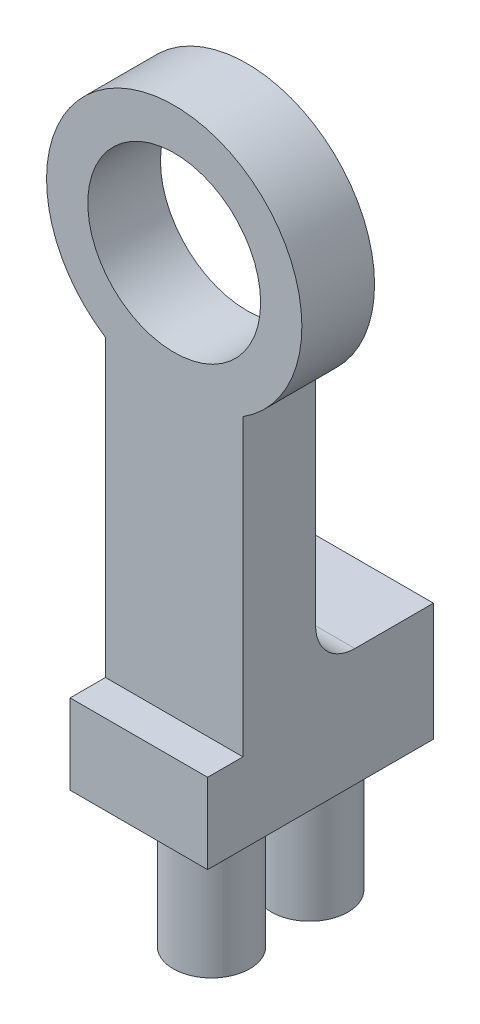
from build123d import *

# Parameters (mm, degrees)
BOSS_EXTRUDE1_DEPTH     = 3.7
SKETCH2_W               = 0.6
SKETCH2_H               = 16.95
CUT_EXTRUDE1_DEPTH      = 10
CUT_EXTRUDE1_DEPTH_BACK = 10
SKETCH3_R               = 2.95
SKETCH3_R_2             = 1.5
BOSS_EXTRUDE2_DEPTH     = 3.1
SKETCH4_R               = 2.5
CUT_EXTRUDE2_DEPTH      = 1.5
SKETCH5_R               = 1.5
BOSS_EXTRUDE3_DEPTH     = 0.4
SKETCH6_R               = 2.95
BOSS_EXTRUDE4_DEPTH     = 2.4
SKETCH7_W               = 22.104564564
SKETCH7_H               = 50.546801486
CUT_EXTRUDE3_DEPTH      = 0.6
SKETCH8_R               = 1.5
BOSS_EXTRUDE5_DEPTH     = 2.6
SKETCH9_R               = 5.5
SKETCH9_R_2             = 3.5
BOSS_EXTRUDE6_DEPTH     = 5.5
SKETCH10_W              = 7
SKETCH10_H              = 7
CUT_EXTRUDE4_DEPTH      = 5.5
SKETCH11_W              = 20.865326807
SKETCH11_H              = 17.809349761
CUT_EXTRUDE5_DEPTH      = 10
SKETCH12_W              = 7
SKETCH12_H              = 6
BOSS_EXTRUDE7_DEPTH     = 6
FILLET1_R               = 2
SKETCH13_R              = 1.95
BOSS_EXTRUDE8_DEPTH     = 7
SKETCH14_R              = 2.95
CUT_EXTRUDE6_DEPTH      = 1.5
SKETCH15_R              = 2.95
BOSS_EXTRUDE9_DEPTH     = 4
SKETCH16_R              = 4.4
CUT_EXTRUDE7_DEPTH      = 34.729104643
SKETCH19_W              = 21.129428132
SKETCH19_H              = 30.590898574
CUT_EXTRUDE10_DEPTH     = 0.3


with BuildPart() as part:
    # Sketch1 → Boss-Extrude1 (new body)
    with BuildSketch(Plane.XY):
        with BuildLine():
            ThreePointArc((3.5, -5.477225575), (0, -6.5), (-3.5, -5.477225575))
            Line((-3.5, -5.477225575), (-3.5, -29.522774425))
            ThreePointArc((-3.5, -29.522774425), (0, -28.5), (3.5, -29.522774425))
            Line((3.5, -29.522774425), (3.5, -5.477225575))
        make_face()
        with BuildLine():
            ThreePointArc((-3.5, -4.242640687), (-4.974937186, -2.34520788), (-5.5, 0))
            ThreePointArc((-5.5, 0), (-4.387482194, 3.31662479), (-1.5, 5.291502622))
            ThreePointArc((-1.5, 5.291502622), (0, 5.5), (1.5, 5.291502622))
            ThreePointArc((1.5, 5.291502622), (4.387482194, 3.31662479), (5.5, 0))
            ThreePointArc((5.5, 0), (4.974937186, -2.34520788), (3.5, -4.242640687))
            Line((3.5, -4.242640687), (3.5, -5.477225575))
            ThreePointArc((3.5, -5.477225575), (5.700877125, -3.122498999), (6.5, 0))
            ThreePointArc((6.5, 0), (-3.122498999, 5.700877125), (-3.5, -5.477225575))
            Line((-3.5, -5.477225575), (-3.5, -4.242640687))
        make_face()
        with BuildLine():
            ThreePointArc((3.5, -4.242640687), (0, -5.5), (-3.5, -4.242640687))
            Line((-3.5, -4.242640687), (-3.5, -5.477225575))
            ThreePointArc((-3.5, -5.477225575), (0, -6.5), (3.5, -5.477225575))
            Line((3.5, -5.477225575), (3.5, -4.242640687))
        make_face()
        with BuildLine():
            ThreePointArc((3.5, 0), (0, -3.5), (-3.5, 0))
            Line((-3.5, 0), (-3.5, -4.242640687))
            ThreePointArc((-3.5, -4.242640687), (0, -5.5), (3.5, -4.242640687))
            Line((3.5, -4.242640687), (3.5, 0))
        make_face()
        with BuildLine():
            ThreePointArc((-3.5, -4.242640687), (-4.974937186, -2.34520788), (-5.5, 0))
            ThreePointArc((-5.5, 0), (-4.387482194, 3.31662479), (-1.5, 5.291502622))
            ThreePointArc((-1.5, 5.291502622), (0, 5.5), (1.5, 5.291502622))
            ThreePointArc((1.5, 5.291502622), (4.387482194, 3.31662479), (5.5, 0))
            ThreePointArc((5.5, 0), (4.974937186, -2.34520788), (3.5, -4.242640687))
            Line((3.5, -4.242640687), (3.5, -5.477225575))
            ThreePointArc((3.5, -5.477225575), (5.700877125, -3.122498999), (6.5, 0))
            ThreePointArc((6.5, 0), (-3.122498999, 5.700877125), (-3.5, -5.477225575))
            Line((-3.5, -5.477225575), (-3.5, -4.242640687))
        make_face()
        with BuildLine():
            ThreePointArc((3.5, -4.242640687), (0, -5.5), (-3.5, -4.242640687))
            Line((-3.5, -4.242640687), (-3.5, -5.477225575))
            ThreePointArc((-3.5, -5.477225575), (0, -6.5), (3.5, -5.477225575))
            Line((3.5, -5.477225575), (3.5, -4.242640687))
        make_face()
        with BuildLine():
            ThreePointArc((3.5, -29.522774425), (0, -28.5), (-3.5, -29.522774425))
            Line((-3.5, -29.522774425), (-3.5, -30.757359313))
            ThreePointArc((-3.5, -30.757359313), (0, -29.5), (3.5, -30.757359313))
            Line((3.5, -30.757359313), (3.5, -29.522774425))
        make_face()
        with BuildLine():
            Line((-3.5, -30.757359313), (-3.5, -29.522774425))
            ThreePointArc((-3.5, -29.522774425), (-3.122498999, -40.700877125), (6.5, -35))
            ThreePointArc((6.5, -35), (5.700877125, -31.877501001), (3.5, -29.522774425))
            Line((3.5, -29.522774425), (3.5, -30.757359313))
            ThreePointArc((3.5, -30.757359313), (4.974937186, -32.65479212), (5.5, -35))
            ThreePointArc((5.5, -35), (4.387482194, -38.31662479), (1.5, -40.291502622))
            ThreePointArc((1.5, -40.291502622), (0, -40.5), (-1.5, -40.291502622))
            ThreePointArc((-1.5, -40.291502622), (-4.387482194, -38.31662479), (-5.5, -35))
            ThreePointArc((-5.5, -35), (-4.974937186, -32.65479212), (-3.5, -30.757359313))
        make_face()
        with BuildLine():
            ThreePointArc((3.5, -29.522774425), (0, -28.5), (-3.5, -29.522774425))
            Line((-3.5, -29.522774425), (-3.5, -30.757359313))
            ThreePointArc((-3.5, -30.757359313), (0, -29.5), (3.5, -30.757359313))
            Line((3.5, -30.757359313), (3.5, -29.522774425))
        make_face()
        with BuildLine():
            Line((-3.5, -30.757359313), (-3.5, -29.522774425))
            ThreePointArc((-3.5, -29.522774425), (-3.122498999, -40.700877125), (6.5, -35))
            ThreePointArc((6.5, -35), (5.700877125, -31.877501001), (3.5, -29.522774425))
            Line((3.5, -29.522774425), (3.5, -30.757359313))
            ThreePointArc((3.5, -30.757359313), (4.974937186, -32.65479212), (5.5, -35))
            ThreePointArc((5.5, -35), (4.387482194, -38.31662479), (1.5, -40.291502622))
            ThreePointArc((1.5, -40.291502622), (0, -40.5), (-1.5, -40.291502622))
            ThreePointArc((-1.5, -40.291502622), (-4.387482194, -38.31662479), (-5.5, -35))
            ThreePointArc((-5.5, -35), (-4.974937186, -32.65479212), (-3.5, -30.757359313))
        make_face()
        with BuildLine():
            ThreePointArc((3.5, -30.757359313), (0, -29.5), (-3.5, -30.757359313))
            Line((-3.5, -30.757359313), (-3.5, -35))
            ThreePointArc((-3.5, -35), (0, -31.5), (3.5, -35))
            Line((3.5, -35), (3.5, -30.757359313))
        make_face()
        with BuildLine():
            Line((-3.5, -35), (-3.5, -30.757359313))
            ThreePointArc((-3.5, -30.757359313), (-4.974937186, -32.65479212), (-5.5, -35))
            Line((-5.5, -35), (-3.5, -35))
        make_face()
        with BuildLine():
            ThreePointArc((5.5, -35), (4.974937186, -32.65479212), (3.5, -30.757359313))
            Line((3.5, -30.757359313), (3.5, -35))
            Line((3.5, -35), (5.5, -35))
        make_face()
        with BuildLine():
            ThreePointArc((3.5, -35), (0, -31.5), (-3.5, -35))
            Line((-3.5, -35), (-2.95, -35))
            ThreePointArc((-2.95, -35), (0, -32.05), (2.95, -35))
            Line((2.95, -35), (3.5, -35))
        make_face()
        with BuildLine():
            Line((-2.95, -35), (-3.5, -35))
            ThreePointArc((-3.5, -35), (-2.958039892, -36.870828693), (-1.5, -38.16227766))
            ThreePointArc((-1.5, -38.16227766), (0, -38.5), (1.5, -38.16227766))
            ThreePointArc((1.5, -38.16227766), (2.958039892, -36.870828693), (3.5, -35))
            Line((3.5, -35), (2.95, -35))
            ThreePointArc((2.95, -35), (0, -37.95), (-2.95, -35))
        make_face()
        with BuildLine():
            ThreePointArc((3.5, -35), (0, -31.5), (-3.5, -35))
            Line((-3.5, -35), (-2.95, -35))
            ThreePointArc((-2.95, -35), (0, -32.05), (2.95, -35))
            Line((2.95, -35), (3.5, -35))
        make_face()
        with BuildLine():
            Line((-2.95, -35), (-3.5, -35))
            ThreePointArc((-3.5, -35), (-2.958039892, -36.870828693), (-1.5, -38.16227766))
            ThreePointArc((-1.5, -38.16227766), (0, -38.5), (1.5, -38.16227766))
            ThreePointArc((1.5, -38.16227766), (2.958039892, -36.870828693), (3.5, -35))
            Line((3.5, -35), (2.95, -35))
            ThreePointArc((2.95, -35), (0, -37.95), (-2.95, -35))
        make_face()
        with BuildLine():
            Line((-1.5, 5.291502622), (-1.5, 3.16227766))
            ThreePointArc((-1.5, 3.16227766), (0, 3.5), (1.5, 3.16227766))
            Line((1.5, 3.16227766), (1.5, 5.291502622))
            ThreePointArc((1.5, 5.291502622), (0, 5.5), (-1.5, 5.291502622))
        make_face()
        with BuildLine():
            Line((-3.5, -4.242640687), (-3.5, 0))
            Line((-3.5, 0), (-5.5, 0))
            ThreePointArc((-5.5, 0), (-4.974937186, -2.34520788), (-3.5, -4.242640687))
        make_face()
        with BuildLine():
            Line((5.5, 0), (3.5, 0))
            Line((3.5, 0), (3.5, -4.242640687))
            ThreePointArc((3.5, -4.242640687), (4.974937186, -2.34520788), (5.5, 0))
        make_face()
        with BuildLine():
            ThreePointArc((-1.5, 3.16227766), (-2.958039892, 1.870828693), (-3.5, 0))
            Line((-3.5, 0), (-2.95, 0))
            ThreePointArc((-2.95, 0), (0, 2.95), (2.95, 0))
            Line((2.95, 0), (3.5, 0))
            ThreePointArc((3.5, 0), (2.958039892, 1.870828693), (1.5, 3.16227766))
            ThreePointArc((1.5, 3.16227766), (0, 3.5), (-1.5, 3.16227766))
        make_face()
        with BuildLine():
            Line((-2.95, 0), (-3.5, 0))
            ThreePointArc((-3.5, 0), (0, -3.5), (3.5, 0))
            Line((3.5, 0), (2.95, 0))
            ThreePointArc((2.95, 0), (0, -2.95), (-2.95, 0))
        make_face()
        with BuildLine():
            ThreePointArc((-1.5, 3.16227766), (-2.958039892, 1.870828693), (-3.5, 0))
            Line((-3.5, 0), (-2.95, 0))
            ThreePointArc((-2.95, 0), (0, 2.95), (2.95, 0))
            Line((2.95, 0), (3.5, 0))
            ThreePointArc((3.5, 0), (2.958039892, 1.870828693), (1.5, 3.16227766))
            ThreePointArc((1.5, 3.16227766), (0, 3.5), (-1.5, 3.16227766))
        make_face()
        with BuildLine():
            Line((-2.95, 0), (-3.5, 0))
            ThreePointArc((-3.5, 0), (0, -3.5), (3.5, 0))
            Line((3.5, 0), (2.95, 0))
            ThreePointArc((2.95, 0), (0, -2.95), (-2.95, 0))
        make_face()
        with BuildLine():
            ThreePointArc((1.5, -38.16227766), (0, -38.5), (-1.5, -38.16227766))
            Line((-1.5, -38.16227766), (-1.5, -40.291502622))
            ThreePointArc((-1.5, -40.291502622), (0, -40.5), (1.5, -40.291502622))
            Line((1.5, -40.291502622), (1.5, -38.16227766))
        make_face()
    extrude(amount=BOSS_EXTRUDE1_DEPTH)

    # Sketch2 → Cut-Extrude1 (cut, two sides)
    with BuildSketch(Plane(origin=(0, 0, 0), x_dir=(0, 0, -1), z_dir=(1, 0, 0))) as cut_extrude1_sk:
        with Locations((-3.4, -33.025)):
            Rectangle(SKETCH2_W, SKETCH2_H)
    extrude(amount=CUT_EXTRUDE1_DEPTH, mode=Mode.SUBTRACT)
    extrude(cut_extrude1_sk.sketch, amount=-CUT_EXTRUDE1_DEPTH_BACK, mode=Mode.SUBTRACT)

    # Sketch3 → Boss-Extrude2 (add)
    with BuildSketch(Plane(origin=(0, 0, 0), x_dir=(-1, 0, 0), z_dir=(0, 0, -1))):
        with Locations((0, -35)):
            Circle(SKETCH3_R)
        with Locations((0, -35)):
            Circle(SKETCH3_R_2, mode=Mode.SUBTRACT)
    extrude(amount=-BOSS_EXTRUDE2_DEPTH)

    # Sketch4 → Cut-Extrude2 (cut)
    with BuildSketch(Plane(origin=(0, 0, 0), x_dir=(-1, 0, 0), z_dir=(0, 0, -1))):
        with Locations((0, -35)):
            Circle(SKETCH4_R)
    extrude(amount=-CUT_EXTRUDE2_DEPTH, mode=Mode.SUBTRACT)

    # Sketch5 → Boss-Extrude3 (add)
    with BuildSketch(Plane.XY.offset(3.1)):
        with BuildLine():
            Line((3.5, -24.55), (-3.5, -24.55))
            Line((-3.5, -24.55), (-3.5, -29.522774425))
            ThreePointArc((-3.5, -29.522774425), (0, -41.5), (3.5, -29.522774425))
            Line((3.5, -29.522774425), (3.5, -24.55))
        make_face()
        with BuildLine():
            Line((-5.5, -35), (-3.5, -35))
            ThreePointArc((-3.5, -35), (-2.958039892, -36.870828693), (-1.5, -38.16227766))
            Line((-1.5, -38.16227766), (-1.5, -40.291502622))
            ThreePointArc((-1.5, -40.291502622), (-4.387482194, -38.31662479), (-5.5, -35))
        make_face(mode=Mode.SUBTRACT)
        with BuildLine():
            ThreePointArc((1.5, -38.16227766), (2.958039892, -36.870828693), (3.5, -35))
            Line((3.5, -35), (5.5, -35))
            ThreePointArc((5.5, -35), (4.387482194, -38.31662479), (1.5, -40.291502622))
            Line((1.5, -40.291502622), (1.5, -38.16227766))
        make_face(mode=Mode.SUBTRACT)
        with Locations(Location((0, -35, 0), (0, 0, 180))):
            Circle(SKETCH5_R, mode=Mode.SUBTRACT)
    extrude(amount=BOSS_EXTRUDE3_DEPTH)

    # Sketch6 → Boss-Extrude4 (add)
    with BuildSketch(Plane.XY.offset(3.7)):
        with BuildLine():
            Line((-3.5, -5.477225575), (-3.5, -24.55))
            Line((-3.5, -24.55), (3.5, -24.55))
            Line((3.5, -24.55), (3.5, -5.477225575))
            ThreePointArc((3.5, -5.477225575), (0, 6.5), (-3.5, -5.477225575))
        make_face()
        Circle(SKETCH6_R, mode=Mode.SUBTRACT)
        with BuildLine():
            Line((-1.5, 5.291502622), (-1.5, 3.16227766))
            ThreePointArc((-1.5, 3.16227766), (-2.958039892, 1.870828693), (-3.5, 0))
            Line((-3.5, 0), (-5.5, 0))
            ThreePointArc((-5.5, 0), (-4.387482194, 3.31662479), (-1.5, 5.291502622))
        make_face(mode=Mode.SUBTRACT)
        with BuildLine():
            Line((1.5, 5.291502622), (1.5, 3.16227766))
            ThreePointArc((1.5, 3.16227766), (2.958039892, 1.870828693), (3.5, 0))
            Line((3.5, 0), (5.5, 0))
            ThreePointArc((5.5, 0), (4.387482194, 3.31662479), (1.5, 5.291502622))
        make_face(mode=Mode.SUBTRACT)
    extrude(amount=BOSS_EXTRUDE4_DEPTH)

    # Sketch7 → Cut-Extrude3 (cut)
    with BuildSketch(Plane.XY):
        with Locations((0.952758093, -17.453923436)):
            Rectangle(SKETCH7_W, SKETCH7_H)
    extrude(amount=CUT_EXTRUDE3_DEPTH, mode=Mode.SUBTRACT)

    # Sketch8 → Boss-Extrude5 (add)
    with BuildSketch(Plane.XY.offset(3.5)):
        with BuildLine():
            Line((-3.5, -24.55), (-3.5, -29.522774425))
            ThreePointArc((-3.5, -29.522774425), (0, -28.5), (3.5, -29.522774425))
            Line((3.5, -29.522774425), (3.5, -24.55))
            Line((3.5, -24.55), (-3.5, -24.55))
        make_face()
        with BuildLine():
            ThreePointArc((-3.5, -35), (-2.958039892, -36.870828693), (-1.5, -38.16227766))
            ThreePointArc((-1.5, -38.16227766), (0, -38.5), (1.5, -38.16227766))
            ThreePointArc((1.5, -38.16227766), (2.958039892, -36.870828693), (3.5, -35))
            ThreePointArc((3.5, -35), (0, -31.5), (-3.5, -35))
        make_face()
        with Locations(Location((0, -35, 0), (0, 0, 180))):
            Circle(SKETCH8_R, mode=Mode.SUBTRACT)
        with BuildLine():
            Line((-5.5, -35), (-3.5, -35))
            ThreePointArc((-3.5, -35), (0, -31.5), (3.5, -35))
            Line((3.5, -35), (5.5, -35))
            ThreePointArc((5.5, -35), (4.062019202, -31.291900756), (0.5, -29.522774425))
            Line((0.5, -29.522774425), (-0.5, -29.522774425))
            ThreePointArc((-0.5, -29.522774425), (-4.062019202, -31.291900756), (-5.5, -35))
        make_face()
        with BuildLine():
            ThreePointArc((1.5, -40.291502622), (0, -40.5), (-1.5, -40.291502622))
            ThreePointArc((-1.5, -40.291502622), (-4.387482194, -38.31662479), (-5.5, -35))
            ThreePointArc((-5.5, -35), (-4.062019202, -31.291900756), (-0.5, -29.522774425))
            Line((-0.5, -29.522774425), (-3.5, -29.522774425))
            ThreePointArc((-3.5, -29.522774425), (-3.122498999, -40.700877125), (6.5, -35))
            ThreePointArc((6.5, -35), (5.700877125, -31.877501001), (3.5, -29.522774425))
            Line((3.5, -29.522774425), (0.5, -29.522774425))
            ThreePointArc((0.5, -29.522774425), (4.062019202, -31.291900756), (5.5, -35))
            ThreePointArc((5.5, -35), (4.387482194, -38.31662479), (1.5, -40.291502622))
        make_face()
        with BuildLine():
            ThreePointArc((1.5, -38.16227766), (0, -38.5), (-1.5, -38.16227766))
            Line((-1.5, -38.16227766), (-1.5, -40.291502622))
            ThreePointArc((-1.5, -40.291502622), (0, -40.5), (1.5, -40.291502622))
            Line((1.5, -40.291502622), (1.5, -38.16227766))
        make_face()
        with BuildLine():
            ThreePointArc((0.5, -29.522774425), (0, -29.5), (-0.5, -29.522774425))
            Line((-0.5, -29.522774425), (0.5, -29.522774425))
        make_face()
        with BuildLine():
            ThreePointArc((1.5, -40.291502622), (0, -40.5), (-1.5, -40.291502622))
            ThreePointArc((-1.5, -40.291502622), (-4.387482194, -38.31662479), (-5.5, -35))
            ThreePointArc((-5.5, -35), (-4.062019202, -31.291900756), (-0.5, -29.522774425))
            Line((-0.5, -29.522774425), (-3.5, -29.522774425))
            ThreePointArc((-3.5, -29.522774425), (-3.122498999, -40.700877125), (6.5, -35))
            ThreePointArc((6.5, -35), (5.700877125, -31.877501001), (3.5, -29.522774425))
            Line((3.5, -29.522774425), (0.5, -29.522774425))
            ThreePointArc((0.5, -29.522774425), (4.062019202, -31.291900756), (5.5, -35))
            ThreePointArc((5.5, -35), (4.387482194, -38.31662479), (1.5, -40.291502622))
        make_face()
        with BuildLine():
            Line((-3.5, -29.522774425), (-0.5, -29.522774425))
            ThreePointArc((-0.5, -29.522774425), (0, -29.5), (0.5, -29.522774425))
            Line((0.5, -29.522774425), (3.5, -29.522774425))
            ThreePointArc((3.5, -29.522774425), (0, -28.5), (-3.5, -29.522774425))
        make_face()
    extrude(amount=BOSS_EXTRUDE5_DEPTH)

    # Sketch9 → Boss-Extrude6 (add)
    with BuildSketch(Plane.XY.offset(6.1)):
        with Locations((0, -35)):
            Circle(SKETCH9_R)
        with Locations((0, -35)):
            Circle(SKETCH9_R_2, mode=Mode.SUBTRACT)
    extrude(amount=-BOSS_EXTRUDE6_DEPTH)

    # Sketch10 → Cut-Extrude4 (cut)
    with BuildSketch(Plane.XY.offset(6.1)):
        with Locations((0, -35)):
            Rectangle(SKETCH10_W, SKETCH10_H)
    extrude(amount=-CUT_EXTRUDE4_DEPTH, mode=Mode.SUBTRACT)

    # Sketch11 → Cut-Extrude5 (cut)
    with BuildSketch(Plane.XY.offset(6.1)):
        with Locations((0.447606021, -33.454674881)):
            Rectangle(SKETCH11_W, SKETCH11_H)
    extrude(amount=-CUT_EXTRUDE5_DEPTH, mode=Mode.SUBTRACT)

    # Sketch12 → Boss-Extrude7 (add)
    with BuildSketch(Plane.XZ.offset(24.55)):
        with Locations((0, -2.4)):
            Rectangle(SKETCH12_W, SKETCH12_H)
    extrude(amount=-BOSS_EXTRUDE7_DEPTH)

    # Fillet1
    fillet1_edges = [part.edges().sort_by_distance(p)[0] for p in [
        (0, -18.55, 0.6),
    ]]
    fillet(fillet1_edges, radius=FILLET1_R)

    # Sketch13 → Boss-Extrude8 (add)
    with BuildSketch(Plane.XZ.offset(24.55)):
        with Locations(Location((0, 2.4, 0), (0, 0, 270))):
            Circle(SKETCH13_R)
        with Locations(Location((0, -2.6, 0), (0, 0, 90))):
            Circle(SKETCH13_R)
    extrude(amount=BOSS_EXTRUDE8_DEPTH)

    # Sketch14 → Cut-Extrude6 (cut)
    with BuildSketch(Plane.XY.offset(6.1)):
        with BuildLine():
            ThreePointArc((3.5, -5.477225575), (0, -6.5), (-3.5, -5.477225575))
            Line((-3.5, -5.477225575), (-3.5, -20.477225575))
            Line((-3.5, -20.477225575), (3.5, -20.477225575))
            Line((3.5, -20.477225575), (3.5, -5.477225575))
        make_face()
        with BuildLine():
            Line((-3.5, -5.477225575), (3.5, -5.477225575))
            ThreePointArc((3.5, -5.477225575), (0, 6.5), (-3.5, -5.477225575))
        make_face()
        with Locations(Location((0, 0, 0), (0, 0, 180))):
            Circle(SKETCH14_R, mode=Mode.SUBTRACT)
        with BuildLine():
            ThreePointArc((3.5, 0), (2.958039892, 1.870828693), (1.5, 3.16227766))
            Line((1.5, 3.16227766), (1.5, 5.291502622))
            ThreePointArc((1.5, 5.291502622), (4.387482194, 3.31662479), (5.5, 0))
            Line((5.5, 0), (3.5, 0))
        make_face(mode=Mode.SUBTRACT)
        with BuildLine():
            ThreePointArc((-1.5, 3.16227766), (-2.958039892, 1.870828693), (-3.5, 0))
            Line((-3.5, 0), (-5.5, 0))
            ThreePointArc((-5.5, 0), (-4.387482194, 3.31662479), (-1.5, 5.291502622))
            Line((-1.5, 5.291502622), (-1.5, 3.16227766))
        make_face(mode=Mode.SUBTRACT)
        with BuildLine():
            Line((3.5, -5.477225575), (-3.5, -5.477225575))
            ThreePointArc((-3.5, -5.477225575), (0, -6.5), (3.5, -5.477225575))
        make_face()
    extrude(amount=-CUT_EXTRUDE6_DEPTH, mode=Mode.SUBTRACT)

    # Sketch15 → Boss-Extrude9 (add)
    with BuildSketch(Plane.XY.offset(4.6)):
        with BuildLine():
            Line((3.5, -20.477225575), (3.5, -5.477225575))
            ThreePointArc((3.5, -5.477225575), (0, 6.5), (-3.5, -5.477225575))
            Line((-3.5, -5.477225575), (-3.5, -20.477225575))
            Line((-3.5, -20.477225575), (3.5, -20.477225575))
        make_face()
        with Locations(Location((0, 0, 0), (0, 0, 180))):
            Circle(SKETCH15_R, mode=Mode.SUBTRACT)
    extrude(amount=-BOSS_EXTRUDE9_DEPTH)

    # Sketch16 → Cut-Extrude7 (cut, through all)
    with BuildSketch(Plane.XY.offset(4.6)):
        Circle(SKETCH16_R)
    extrude(amount=-CUT_EXTRUDE7_DEPTH, mode=Mode.SUBTRACT)

    # Sketch19 → Cut-Extrude10 (cut)
    with BuildSketch(Plane.XY.offset(4.6)):
        with Locations((-0.188655608, -5.181776288)):
            Rectangle(SKETCH19_W, SKETCH19_H)
    extrude(amount=-CUT_EXTRUDE10_DEPTH, mode=Mode.SUBTRACT)


solid = part.part
